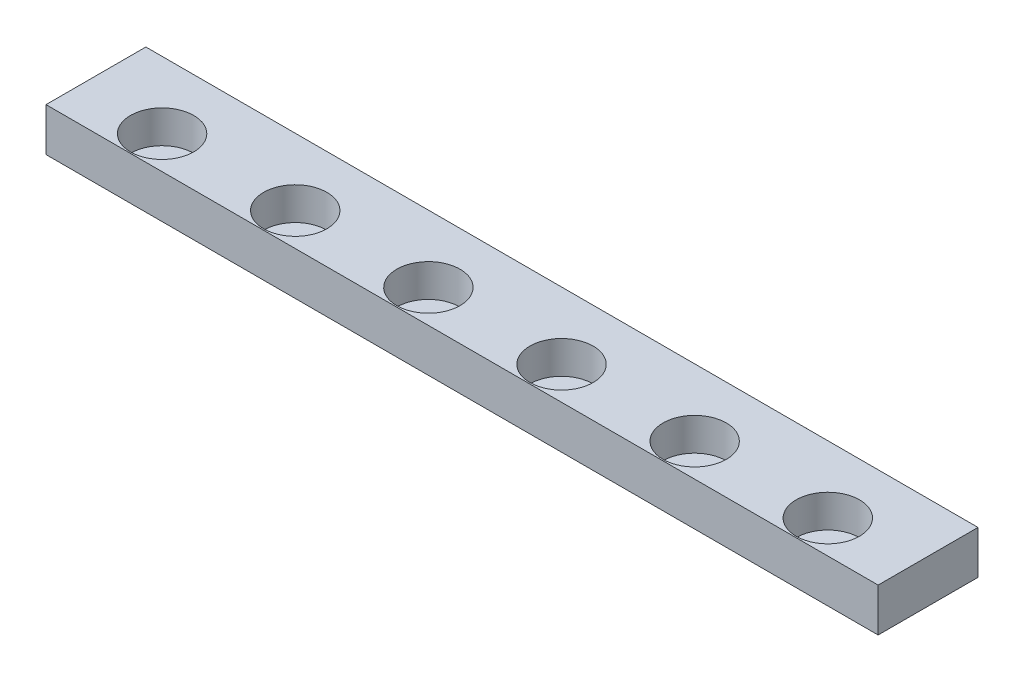
from build123d import *

# Parameters (mm, degrees)
SKETCH1_W           = 63.5
SKETCH1_H           = 7.62
BOSS_EXTRUDE1_DEPTH = 3.302
SKETCH3_R           = 2.413
CUT_EXTRUDE3_DEPTH  = 2.5


with BuildPart() as part:
    # Sketch1 → Boss-Extrude1 (new body)
    with BuildSketch(Plane(origin=(0, 0, 0), x_dir=(1, 0, 0), z_dir=(0, 1, 0))):
        Rectangle(SKETCH1_W, SKETCH1_H)
    extrude(amount=BOSS_EXTRUDE1_DEPTH)

    # Sketch3 → Cut-Extrude3 (cut)
    with BuildSketch(Plane(origin=(0, 3.302, 0), x_dir=(1, 0, 0), z_dir=(0, 1, 0))):
        with Locations((-5.08, -1.3)):
            Circle(SKETCH3_R)
        with Locations((5.08, -1.3)):
            Circle(SKETCH3_R)
        with Locations((15.24, -1.3)):
            Circle(SKETCH3_R)
        with Locations((25.4, -1.3)):
            Circle(SKETCH3_R)
        with Locations((-15.24, -1.3)):
            Circle(SKETCH3_R)
        with Locations((-25.4, -1.3)):
            Circle(SKETCH3_R)
    extrude(amount=-CUT_EXTRUDE3_DEPTH, mode=Mode.SUBTRACT)


solid = part.part
